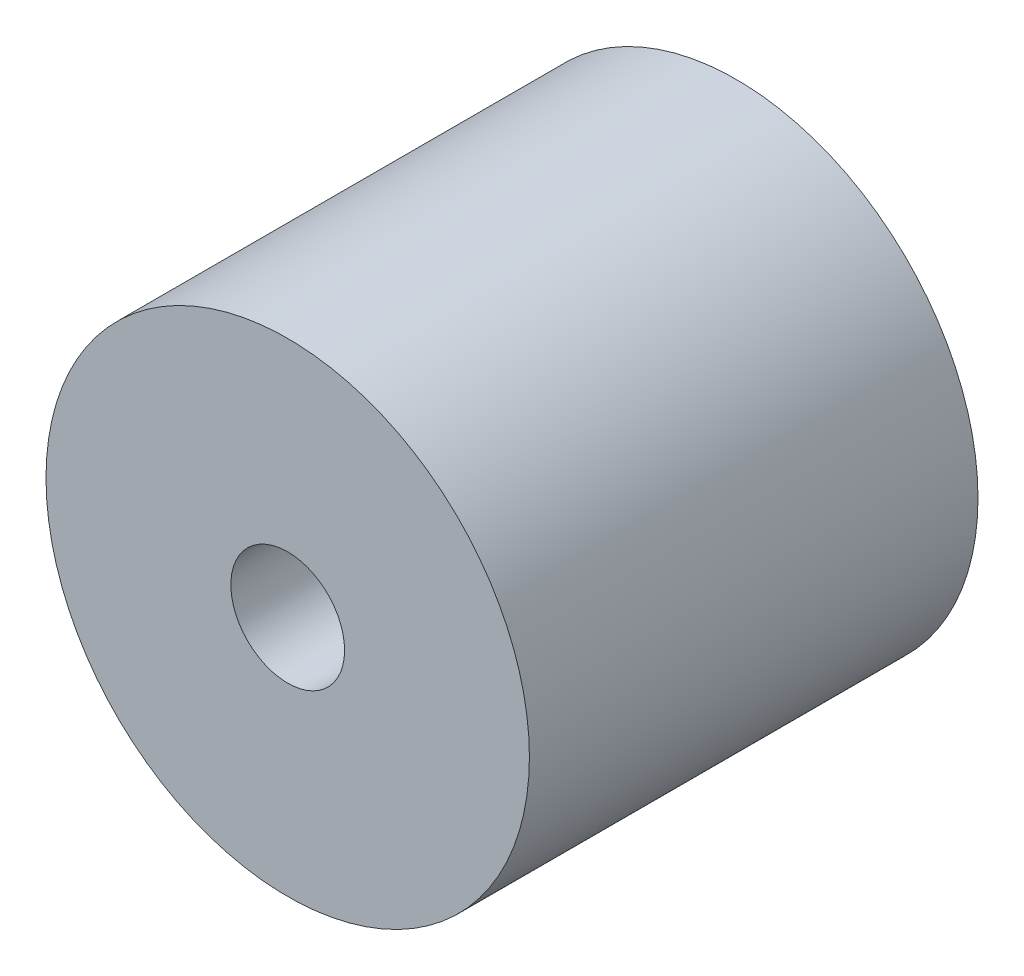
from build123d import *

# Parameters (mm, degrees)
SKETCH1_R           = 34
SKETCH1_R_2         = 8
BOSS_EXTRUDE1_DEPTH = 31.55
SHELL1_T            = 3.5


with BuildPart() as part:
    # Sketch1 → Boss-Extrude1 (new, symmetric)
    with BuildSketch(Plane.XY):
        Circle(SKETCH1_R)
        Circle(SKETCH1_R_2, mode=Mode.SUBTRACT)
    extrude(amount=BOSS_EXTRUDE1_DEPTH, both=True)

    # Shell1 (no face opened: a closed hollow body)
    add(offset(amount=-SHELL1_T, mode=Mode.PRIVATE), mode=Mode.SUBTRACT)


solid = part.part
